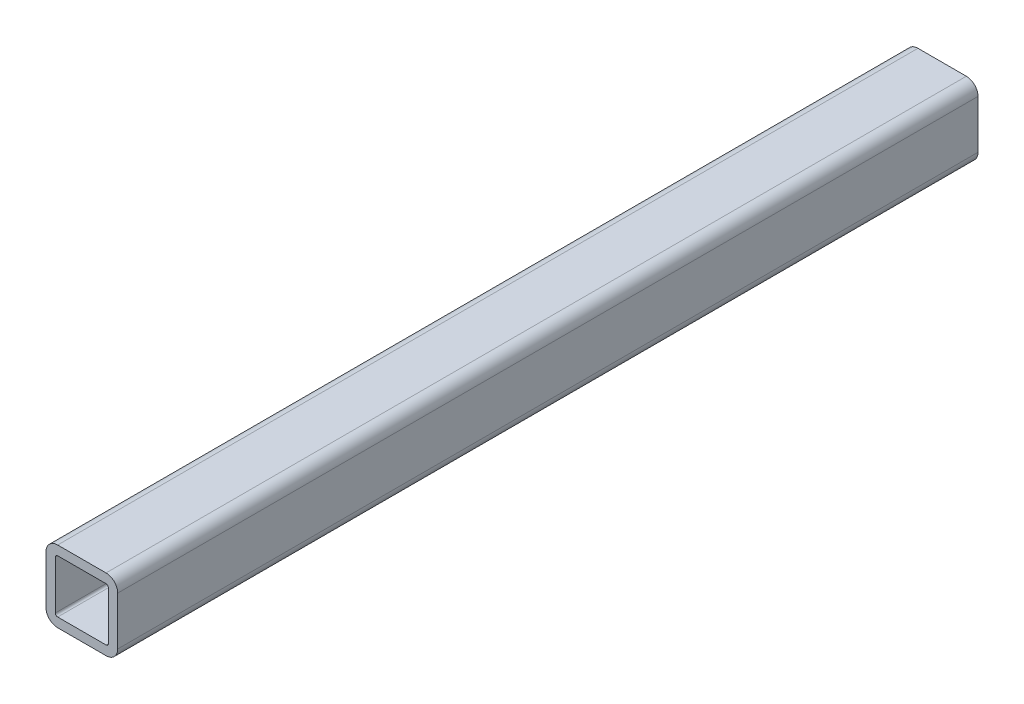
from build123d import *

# Parameters (mm, degrees)
BOSS_EXTRUDE1_DEPTH = 76.2


with BuildPart() as part:
    # Sketch4 → Boss-Extrude1 (new body, symmetric)
    with BuildSketch(Plane.XY):
        with BuildLine():
            Line((6.35, -4.28625), (6.35, 4.28625))
            ThreePointArc((6.35, 4.28625), (5.74554162, 5.74554162), (4.28625, 6.35))
            Line((4.28625, 6.35), (-4.28625, 6.35))
            ThreePointArc((-4.28625, 6.35), (-5.74554162, 5.74554162), (-6.35, 4.28625))
            Line((-6.35, 4.28625), (-6.35, -4.28625))
            ThreePointArc((-6.35, -4.28625), (-5.74554162, -5.74554162), (-4.28625, -6.35))
            Line((-4.28625, -6.35), (4.28625, -6.35))
            ThreePointArc((4.28625, -6.35), (5.74554162, -5.74554162), (6.35, -4.28625))
        make_face()
        with BuildLine():
            Line((4.699, 4.28625), (4.699, -4.28625))
            ThreePointArc((4.699, -4.28625), (4.578108324, -4.578108324), (4.28625, -4.699))
            Line((4.28625, -4.699), (-4.28625, -4.699))
            ThreePointArc((-4.28625, -4.699), (-4.578108324, -4.578108324), (-4.699, -4.28625))
            Line((-4.699, -4.28625), (-4.699, 4.28625))
            ThreePointArc((-4.699, 4.28625), (-4.578108324, 4.578108324), (-4.28625, 4.699))
            Line((-4.28625, 4.699), (4.28625, 4.699))
            ThreePointArc((4.28625, 4.699), (4.578108324, 4.578108324), (4.699, 4.28625))
        make_face(mode=Mode.SUBTRACT)
    extrude(amount=BOSS_EXTRUDE1_DEPTH, both=True)


solid = part.part
